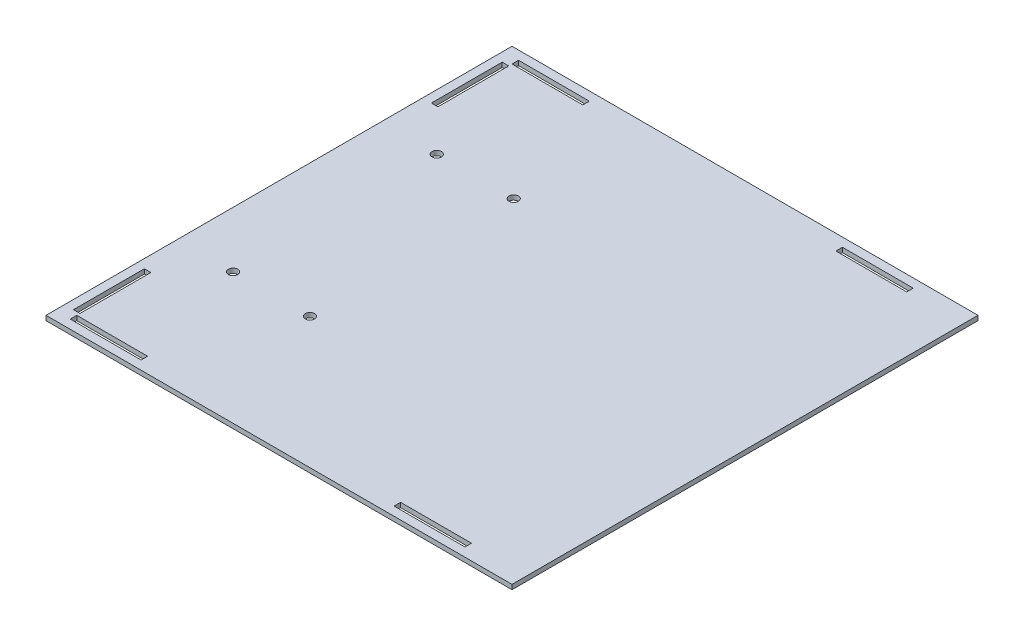
from build123d import *

# Parameters (mm, degrees)
SKETCH1_W                  = 254
SKETCH1_H                  = 127
SKETCH1_W_2                = 38.608
SKETCH1_H_2                = 3.556
SKETCH1_W_3                = 3.556
SKETCH1_H_3                = 38.608
BOSS_EXTRUDE1_DEPTH        = 2.54
F_7_0_201_DIAMETER_HOLE1_D = 5.1054


with BuildPart() as part:
    # Sketch1 → Boss-Extrude1 (new body)
    with BuildSketch(Plane(origin=(0, 0, 0), x_dir=(1, 0, 0), z_dir=(0, 1, 0))):
        with Locations((127, 0)):
            Rectangle(SKETCH1_W, SKETCH1_H)
        with Locations((27.686, 56.896)):
            Rectangle(SKETCH1_W_2, SKETCH1_H_2, mode=Mode.SUBTRACT)
        with Locations((204.216, 56.896)):
            Rectangle(SKETCH1_W_2, SKETCH1_H_2, mode=Mode.SUBTRACT)
        with Locations((6.604, 34.036)):
            Rectangle(SKETCH1_W_3, SKETCH1_H_3, mode=Mode.SUBTRACT)
    boss_extrude1 = extrude(amount=BOSS_EXTRUDE1_DEPTH)

    # #7 (0.201) Diameter Hole1 (through all)
    with Locations(Plane(origin=(30.48, 2.54, 7.9756), x_dir=(0, 0, 1), z_dir=(0, 1, 0))):
        with Locations((0, 0), (0, 41.91)):
            f_7_0_201_diameter_hole1 = Hole(F_7_0_201_DIAMETER_HOLE1_D / 2)

    # Mirror1: Boss-Extrude1, #7 (0.201) Diameter Hole1 across plane
    add(boss_extrude1.mirror(Plane(origin=(0, 2.54, 63.5), x_dir=(1, 0, 0), z_dir=(0, 0, -1))))
    add(f_7_0_201_diameter_hole1.mirror(Plane(origin=(0, 2.54, 63.5), x_dir=(1, 0, 0), z_dir=(0, 0, -1))), mode=Mode.SUBTRACT)


solid = part.part
